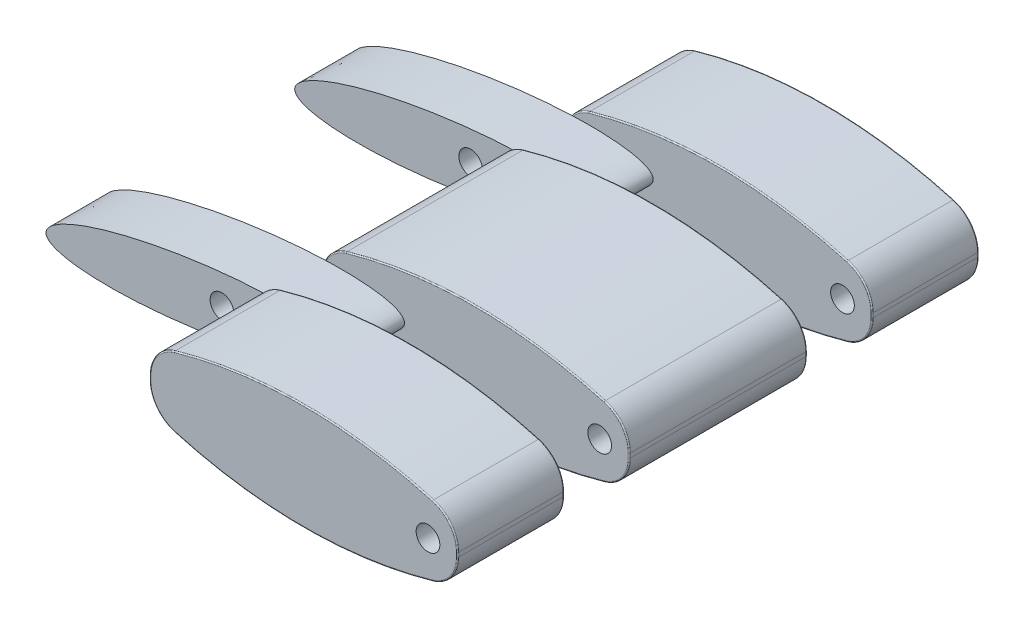
from build123d import *

# Parameters (mm, degrees)
BOSS_EXTRUDE1_DEPTH     = 22
SKETCH2_W               = 20.821066257
SKETCH2_H               = 2.75
SKETCH2_W_2             = 22.326203578
CUT_EXTRUDE1_DEPTH      = 11
CUT_EXTRUDE2_START      = -0.5
SKETCH3_R               = 0.5
CUT_EXTRUDE2_DEPTH      = 21
FILLET1_R               = 0.05
FILLET2_R               = 0.05
FILLET3_R               = 0.05
SKETCH4_R               = 0.5
CUT_EXTRUDE3_DEPTH      = 30
BOSS_EXTRUDE2_START     = -4.5
SKETCH6_RX              = 6.381317706
SKETCH6_RY              = 1.230977933
BOSS_EXTRUDE2_DEPTH     = 2.5
BOSS_EXTRUDE3_START     = -17.5
SKETCH6_2_RX            = 6.381317706
SKETCH6_2_RY            = 1.230977933
BOSS_EXTRUDE3_DEPTH     = 2.5
SKETCH7_R               = 0.5
CUT_EXTRUDE6_DEPTH      = 22.5
CUT_EXTRUDE7_REACH      = 38.935
CUT_EXTRUDE7_END_RADIUS = 19.554545455
CUT_EXTRUDE7_START      = -10
FILLET4_R               = 0.02


with BuildPart() as part:
    # Sketch1 → Boss-Extrude1 (new body)
    with BuildSketch(Plane.XY):
        with BuildLine():
            Line((-6.5, 0.089598011), (-6.5, -0.089598011))
            ThreePointArc((-6.5, -0.089598011), (-6.208135141, -0.962078954), (-5.450037249, -1.483323307))
            ThreePointArc((-5.450037249, -1.483323307), (0, -2.25), (5.450037249, -1.483323307))
            ThreePointArc((5.450037249, -1.483323307), (6.208135141, -0.962078954), (6.5, -0.089598011))
            Line((6.5, -0.089598011), (6.5, 0.089598011))
            ThreePointArc((6.5, 0.089598011), (6.208135141, 0.962078954), (5.450037249, 1.483323307))
            ThreePointArc((5.450037249, 1.483323307), (0, 2.25), (-5.450037249, 1.483323307))
            ThreePointArc((-5.450037249, 1.483323307), (-6.208135141, 0.962078954), (-6.5, 0.089598011))
        make_face()
    extrude(amount=BOSS_EXTRUDE1_DEPTH)

    # Sketch2 → Cut-Extrude1 (cut, symmetric)
    with BuildSketch(Plane(origin=(0, 0, 0), x_dir=(1, 0, 0), z_dir=(0, 1, 0))):
        with Locations((-0.407641358, -5.875)):
            Rectangle(SKETCH2_W, SKETCH2_H)
        with Locations((1.37970921, -16.125)):
            Rectangle(SKETCH2_W_2, SKETCH2_H)
    extrude(amount=CUT_EXTRUDE1_DEPTH, both=True, mode=Mode.SUBTRACT)


with BuildPart() as cut_extrude1_piece_1:
    # of the separate pieces the step leaves, piece 1, a body of its own (cut_extrude1_pieces)
    add(part.part.solids().sort_by_distance((6.5, -0.089598011, 7.25))[0])


with BuildPart() as cut_extrude1_piece_2:
    # of the separate pieces the step leaves, piece 2, a body of its own (cut_extrude1_pieces)
    add(part.part.solids().sort_by_distance((6.5, -0.089598011, 17.5))[0])


with BuildPart() as cut_extrude1_piece_3:
    # of the separate pieces the step leaves, piece 3, a body of its own (cut_extrude1_pieces)
    add(part.part.solids().sort_by_distance((5.450037249, -1.483323307, 0))[0])


with BuildPart() as cut_extrude2_tool:
    # Sketch3 → Cut-Extrude2 (new body)
    with BuildSketch(Plane.XY.offset(22).offset(CUT_EXTRUDE2_START)):
        with Locations((5.25, 0)):
            Circle(SKETCH3_R)
        with Locations((-5.25, 0)):
            Circle(SKETCH3_R)
    extrude(amount=-CUT_EXTRUDE2_DEPTH)


with BuildPart() as cut_extrude1_piece_1_1:
    add(cut_extrude1_piece_1.part)

    # Cut-Extrude2: cut by cut_extrude2_tool
    add(cut_extrude2_tool.part, mode=Mode.SUBTRACT)

    # Fillet2
    fillet2_edges = [cut_extrude1_piece_1_1.edges().sort_by_distance(p)[0] for p in [
        (6.5, 0, 14.75),
        (6.5, 0, 7.25),
        (6.208135141, -0.962078954, 14.75),
        (6.208135141, -0.962078954, 7.25),
        (0, -2.25, 14.75),
        (0, -2.25, 7.25),
        (-6.208135141, -0.962078954, 14.75),
        (-6.208135141, -0.962078954, 7.25),
        (-6.5, 0, 14.75),
        (-6.5, 0, 7.25),
        (-6.208135141, 0.962078954, 14.75),
        (-6.208135141, 0.962078954, 7.25),
        (0, 2.25, 14.75),
        (0, 2.25, 7.25),
        (6.208135141, 0.962078954, 14.75),
        (6.208135141, 0.962078954, 7.25),
    ]]
    fillet(fillet2_edges, radius=FILLET2_R)


with BuildPart() as cut_extrude1_piece_2_1:
    add(cut_extrude1_piece_2.part)

    # Cut-Extrude2: cut by cut_extrude2_tool
    add(cut_extrude2_tool.part, mode=Mode.SUBTRACT)

    # Fillet1
    fillet1_edges = [cut_extrude1_piece_2_1.edges().sort_by_distance(p)[0] for p in [
        (-6.208135141, 0.962078954, 22),
        (-6.5, 0, 22),
        (-6.208135141, -0.962078954, 22),
        (0, -2.25, 22),
        (6.208135141, -0.962078954, 22),
        (6.5, 0, 22),
        (6.208135141, 0.962078954, 22),
        (6.208135141, 0.962078954, 17.5),
        (6.208135141, -0.962078954, 17.5),
        (6.5, 0, 17.5),
        (0, 2.25, 17.5),
        (-6.208135141, 0.962078954, 17.5),
        (-6.5, 0, 17.5),
        (-6.208135141, -0.962078954, 17.5),
        (0, -2.25, 17.5),
        (0, 2.25, 22),
    ]]
    fillet(fillet1_edges, radius=FILLET1_R)


with BuildPart() as cut_extrude1_piece_3_1:
    add(cut_extrude1_piece_3.part)

    # Cut-Extrude2: cut by cut_extrude2_tool
    add(cut_extrude2_tool.part, mode=Mode.SUBTRACT)

    # Fillet3
    fillet3_edges = [cut_extrude1_piece_3_1.edges().sort_by_distance(p)[0] for p in [
        (6.208135141, 0.962078954, 4.5),
        (6.208135141, 0.962078954, 0),
        (0, 2.25, 4.5),
        (0, 2.25, 0),
        (-6.208135141, 0.962078954, 4.5),
        (-6.208135141, 0.962078954, 0),
        (-6.5, 0, 4.5),
        (-6.5, 0, 0),
        (-6.208135141, -0.962078954, 4.5),
        (-6.208135141, -0.962078954, 0),
        (0, -2.25, 4.5),
        (0, -2.25, 0),
        (6.208135141, -0.962078954, 4.5),
        (6.208135141, -0.962078954, 0),
        (6.5, 0, 4.5),
        (6.5, 0, 0),
    ]]
    fillet(fillet3_edges, radius=FILLET3_R)


with BuildPart() as cut_extrude3_tool:
    # Sketch4 → Cut-Extrude3 (new, symmetric)
    with BuildSketch(Plane.XY.offset(4.5)):
        with Locations((5.25, 0)):
            Circle(SKETCH4_R)
    extrude(amount=CUT_EXTRUDE3_DEPTH, both=True)


with BuildPart() as cut_extrude1_piece_2_2:
    add(cut_extrude1_piece_2_1.part)

    # Cut-Extrude3: cut by cut_extrude3_tool
    add(cut_extrude3_tool.part, mode=Mode.SUBTRACT)

    # Sketch6 → Boss-Extrude2 (add)
    with BuildSketch(Plane.XY.offset(22).offset(BOSS_EXTRUDE2_START)):
        with Locations(Location((-9.058816325, -0.515837668), (0, 0, 8.239325628))):
            Ellipse(SKETCH6_RX, SKETCH6_RY)
    extrude(amount=-BOSS_EXTRUDE2_DEPTH)


with BuildPart() as cut_extrude1_piece_3_2:
    add(cut_extrude1_piece_3_1.part)

    # Cut-Extrude3: cut by cut_extrude3_tool
    add(cut_extrude3_tool.part, mode=Mode.SUBTRACT)

    # Sketch6_2 → Boss-Extrude3 (add)
    with BuildSketch(Plane.XY.offset(22).offset(BOSS_EXTRUDE3_START)):
        with Locations(Location((-9.058816325, -0.515837668), (0, 0, 8.239325628))):
            Ellipse(SKETCH6_2_RX, SKETCH6_2_RY)
    extrude(amount=BOSS_EXTRUDE3_DEPTH)


with BuildPart() as cut_extrude6_tool:
    # Sketch7 → Cut-Extrude6 (new body)
    with BuildSketch(Plane.XY.offset(17.5)):
        with Locations((-7.947567337, -0.377382917)):
            Circle(SKETCH7_R)
    extrude(amount=-CUT_EXTRUDE6_DEPTH)


with BuildPart() as cut_extrude1_piece_2_3:
    add(cut_extrude1_piece_2_2.part)

    # Cut-Extrude6: cut by cut_extrude6_tool
    add(cut_extrude6_tool.part, mode=Mode.SUBTRACT)

    # Cut-Extrude7: up to this cylinder (the profile starts outside it)
    cut_extrude7_end = Plane(origin=(0, 17.504545455, 19.722134), z_dir=(0, 0, -1)) * Cylinder(CUT_EXTRUDE7_END_RADIUS, 117.979090909, mode=Mode.PRIVATE)
    # Sketch8 → Cut-Extrude7 (cut, up to the surface)
    with BuildSketch(Plane(origin=(0, 0, 0), x_dir=(1, 0, 0), z_dir=(0, 1, 0)).offset(CUT_EXTRUDE7_START), mode=Mode.PRIVATE) as cut_extrude7_sk1:
        Polygon((-0.2, -20.788940276), (0.2, -20.788940276), (0.2, -19.288940276), (0.45, -19.288940276), (0, -18.638940276), (-0.45, -19.288940276), (-0.2, -19.288940276), align=None)
    cut_extrude7_tool1 = extrude(cut_extrude7_sk1.sketch, amount=CUT_EXTRUDE7_REACH, mode=Mode.PRIVATE) - cut_extrude7_end
    add(cut_extrude7_tool1.solids().sort_by_distance((0, -10, 19.722134))[0], mode=Mode.SUBTRACT)

    # Fillet4
    fillet4_edges = [cut_extrude1_piece_2_3.edges().sort_by_distance(p)[0] for p in [
        (0.2, -2.248987549, 20.038940276),
        (0, -2.25, 20.788940276),
        (-0.2, -2.248987549, 20.038940276),
        (-0.325006508, -2.247326277, 19.288940276),
        (-0.22500473, -2.248718554, 18.963947108),
        (0.22500473, -2.248718554, 18.963947108),
        (0.325006508, -2.247326277, 19.288940276),
        (0.325006642, -2.047298924, 19.288940276),
        (0.225004827, -2.048705446, 18.963947249),
        (-0.225004827, -2.048705446, 18.963947249),
        (-0.325006642, -2.047298924, 19.288940276),
        (-0.2, -2.048977193, 20.038940276),
        (0, -2.05, 20.788940276),
        (0.2, -2.048977193, 20.038940276),
    ]]
    fillet(fillet4_edges, radius=FILLET4_R)


with BuildPart() as cut_extrude1_piece_3_3:
    add(cut_extrude1_piece_3_2.part)

    # Cut-Extrude6: cut by cut_extrude6_tool
    add(cut_extrude6_tool.part, mode=Mode.SUBTRACT)


solid = Compound([cut_extrude1_piece_1_1.part, cut_extrude1_piece_2_3.part, cut_extrude1_piece_3_3.part])
